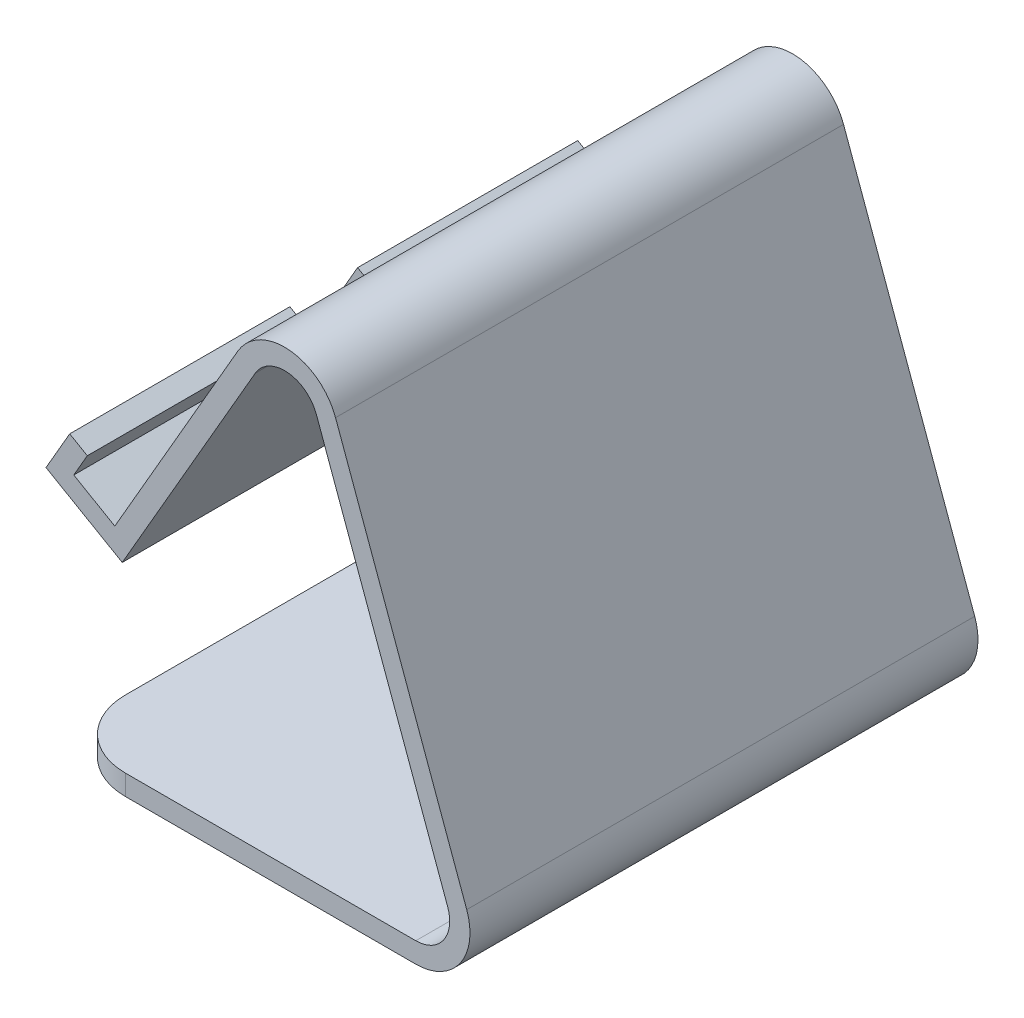
from build123d import *

# Parameters (mm, degrees)
EXTRUDE_2_DEPTH     = 37.5
SKETCH_2_W          = 10
SKETCH_2_H          = 15
CUT_EXTRUDE_2_DEPTH = 20
FILLET_1_R          = 10
FILLET_2_R          = 10
CUT_EXTRUDE_3_DEPTH = 15


with BuildPart() as part:
    # 草图1 → 凸台-拉伸2 (new body, symmetric)
    with BuildSketch(Plane.XY):
        with BuildLine():
            Line((0, 0), (52.859259966, 0))
            ThreePointArc((52.859259966, 0), (56.955020188, 2.132117818), (57.55772307, 6.710100717))
            Line((57.55772307, 6.710100717), (38.189406423, 59.924113358))
            ThreePointArc((38.189406423, 59.924113358), (33.926722033, 63.194986132), (29.1608163, 60.714012641))
            Line((29.1608163, 60.714012641), (9.522083601, 26.698729811))
            Line((9.522083601, 26.698729811), (-1.736246648, 33.198729811))
            Line((-1.736246648, 33.198729811), (1.763753352, 39.260907637))
            Line((1.763753352, 39.260907637), (4.361829564, 37.760907637))
            Line((4.361829564, 37.760907637), (2.361829564, 34.296806022))
            Line((2.361829564, 34.296806022), (8.42400739, 30.796806022))
            Line((8.42400739, 30.796806022), (26.562740089, 62.214012641))
            ThreePointArc((26.562740089, 62.214012641), (34.188189261, 66.183570226), (41.008484285, 60.950173788))
            Line((41.008484285, 60.950173788), (60.376800933, 7.736161147))
            ThreePointArc((60.376800933, 7.736161147), (59.412476321, 0.411388509), (52.859259966, -3))
            Line((52.859259966, -3), (0, -3))
            Line((0, -3), (0, 0))
        make_face()
    extrude(amount=EXTRUDE_2_DEPTH, both=True)

    # 草图2 → 切除-拉伸2 (cut)
    with BuildSketch(Plane(origin=(-15.677656681, 9.051499305, 0), x_dir=(0, 0, 1), z_dir=(-0.866025404, 0.5, 0))):
        with Locations((0, 27.882820066)):
            Rectangle(SKETCH_2_W, SKETCH_2_H)
    extrude(amount=-CUT_EXTRUDE_2_DEPTH, mode=Mode.SUBTRACT)

    # 圆角1
    fillet_1_edges = [part.edges().sort_by_distance(p)[0] for p in [
        (0, -1.5, -37.5),
    ]]
    fillet(fillet_1_edges, radius=FILLET_1_R)

    # 圆角2
    fillet_2_edges = [part.edges().sort_by_distance(p)[0] for p in [
        (0, -1.5, 37.5),
    ]]
    fillet(fillet_2_edges, radius=FILLET_2_R)

    # 草图3 → 切除-拉伸3 (cut)
    with BuildSketch(Plane(origin=(-7.017402643, 4.051499305, 0), x_dir=(0, 0, 1), z_dir=(-0.866025404, 0.5, 0))):
        Polygon((-1.341883091, 59.052563915), (-10.735064726, 45.214394542), (6.122341602, 45.214394542), align=None)
    extrude(amount=-CUT_EXTRUDE_3_DEPTH, mode=Mode.SUBTRACT)


solid = part.part
